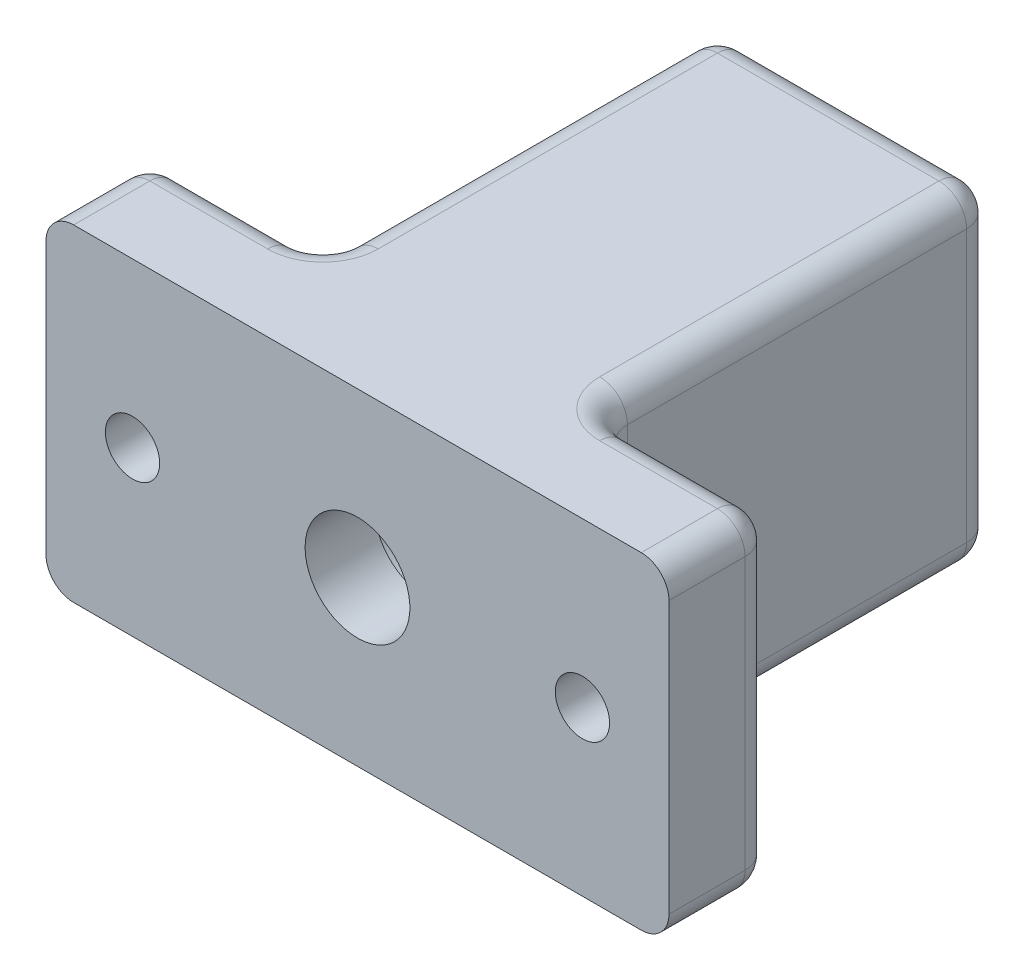
from build123d import *

# Parameters (mm, degrees)
SKETCH3_W              = 57.15
SKETCH3_H              = 30
SKETCH3_R              = 12.7
BOSS_EXTRUDE1_DEPTH    = 9.525
SKETCH6_W              = 25.4
SKETCH6_H              = 30
SKETCH6_R              = 11.684
BOSS_EXTRUDE2_DEPTH    = 36.195
F_10_CLEARANCE_HOLE1_D = 4.9784
FILLET2_R              = 2.54


with BuildPart() as part:
    # Sketch1 → Revolve1 (revolve)
    with BuildSketch(Plane(origin=(0, 0, 0), x_dir=(1, 0, 0), z_dir=(0, 1, 0)), mode=Mode.PRIVATE) as revolve1_sk:
        Polygon((4.80625, 6.35), (4.80625, 0), (12.7, 0), (12.7, 45.72), (4.7625, 45.72), (4.7625, 41.91), (6.790625, 41.91), (6.790625, 6.35), align=None)
    revolve(revolve1_sk.sketch.rotate(Axis((0, 0, 0), (0, 0, 1)), 180), axis=Axis((0, 0, 0), (0, 0, 1)))  # turned: the seam where the file's is

    # Sketch3 → Boss-Extrude1 (add)
    with BuildSketch(Plane(origin=(0, 0, 0), x_dir=(-1, 0, 0), z_dir=(0, 0, -1))):
        Rectangle(SKETCH3_W, SKETCH3_H)
        Circle(SKETCH3_R, mode=Mode.SUBTRACT)
    extrude(amount=BOSS_EXTRUDE1_DEPTH)

    # Sketch6 → Boss-Extrude2 (add)
    with BuildSketch(Plane(origin=(0, 0, -9.525), x_dir=(-1, 0, 0), z_dir=(0, 0, -1))):
        Rectangle(SKETCH6_W, SKETCH6_H)
        Circle(SKETCH6_R, mode=Mode.SUBTRACT)
    extrude(amount=BOSS_EXTRUDE2_DEPTH)

    # #10 Clearance Hole1 (through all)
    with Locations(Plane(origin=(0, 0, -9.525), x_dir=(-1, 0, 0), z_dir=(0, 0, -1))):
        with Locations((20.6375, 0), (-20.6375, 0)):
            Hole(F_10_CLEARANCE_HOLE1_D / 2)

    # Fillet2
    fillet2_edges = [part.edges().sort_by_distance(p)[0] for p in [
        (28.575, 0, -9.525),
        (20.6375, -15, -9.525),
        (-28.575, 0, -9.525),
        (-20.6375, 15, -9.525),
        (28.575, 15, -4.7625),
        (28.575, -15, -4.7625),
        (-28.575, -15, -4.7625),
        (-28.575, 15, -4.7625),
        (20.6375, 15, -9.525),
        (-20.6375, -15, -9.525),
        (12.7, 0, -9.525),
        (12.7, 0, -45.72),
        (12.7, 15, -27.6225),
        (-12.7, 0, -9.525),
        (-12.7, 0, -45.72),
        (-12.7, -15, -27.6225),
        (0, -15, -45.72),
        (12.7, -15, -27.6225),
        (0, 15, -45.72),
        (-12.7, 15, -27.6225),
        (4.7625, 0, -45.72),
    ]]
    fillet(fillet2_edges, radius=FILLET2_R)


solid = part.part
